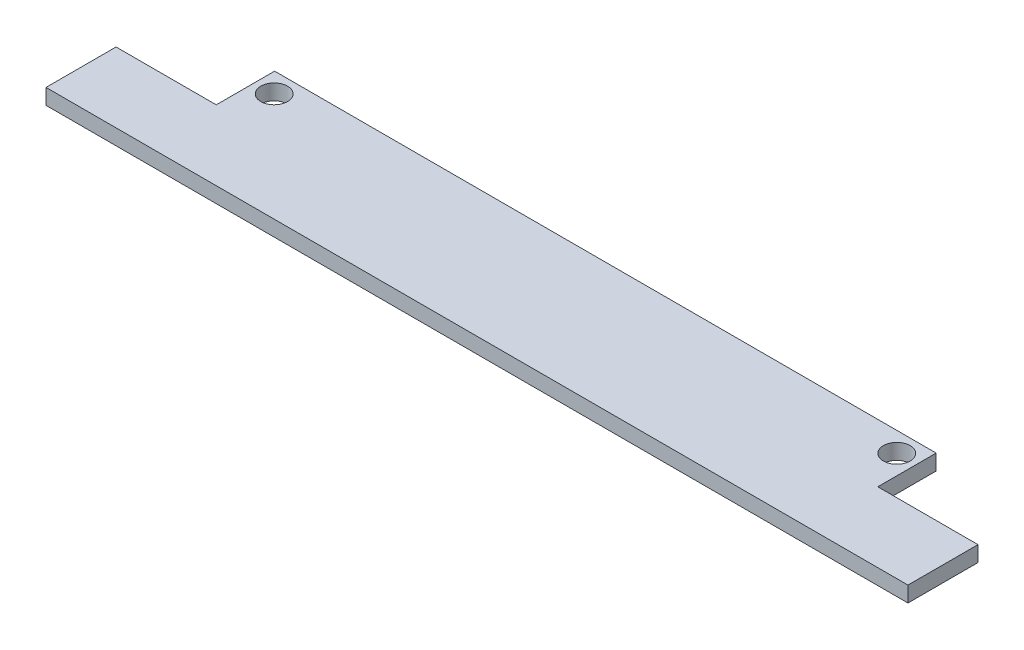
from build123d import *

# Parameters (mm, degrees)
SKETCH1_W           = 88.6
SKETCH1_H           = 7.2
SKETCH1_W_2         = 68
SKETCH1_H_2         = 6
SKETCH1_R           = 1.375
BOSS_EXTRUDE1_DEPTH = 1.6


with BuildPart() as part:
    # Sketch1 → Boss-Extrude1 (new body)
    with BuildSketch(Plane(origin=(0, 0, 0), x_dir=(1, 0, 0), z_dir=(0, 1, 0))):
        with Locations((9.305038693, -28.915060123)):
            Rectangle(SKETCH1_W, SKETCH1_H)
        with Locations((9.305038693, -22.315060123)):
            Rectangle(SKETCH1_W_2, SKETCH1_H_2)
        with Locations((-22.694961307, -21.362291366)):
            Circle(SKETCH1_R, mode=Mode.SUBTRACT)
        with Locations((41.305038693, -21.362291366)):
            Circle(SKETCH1_R, mode=Mode.SUBTRACT)
    extrude(amount=BOSS_EXTRUDE1_DEPTH)


solid = part.part
